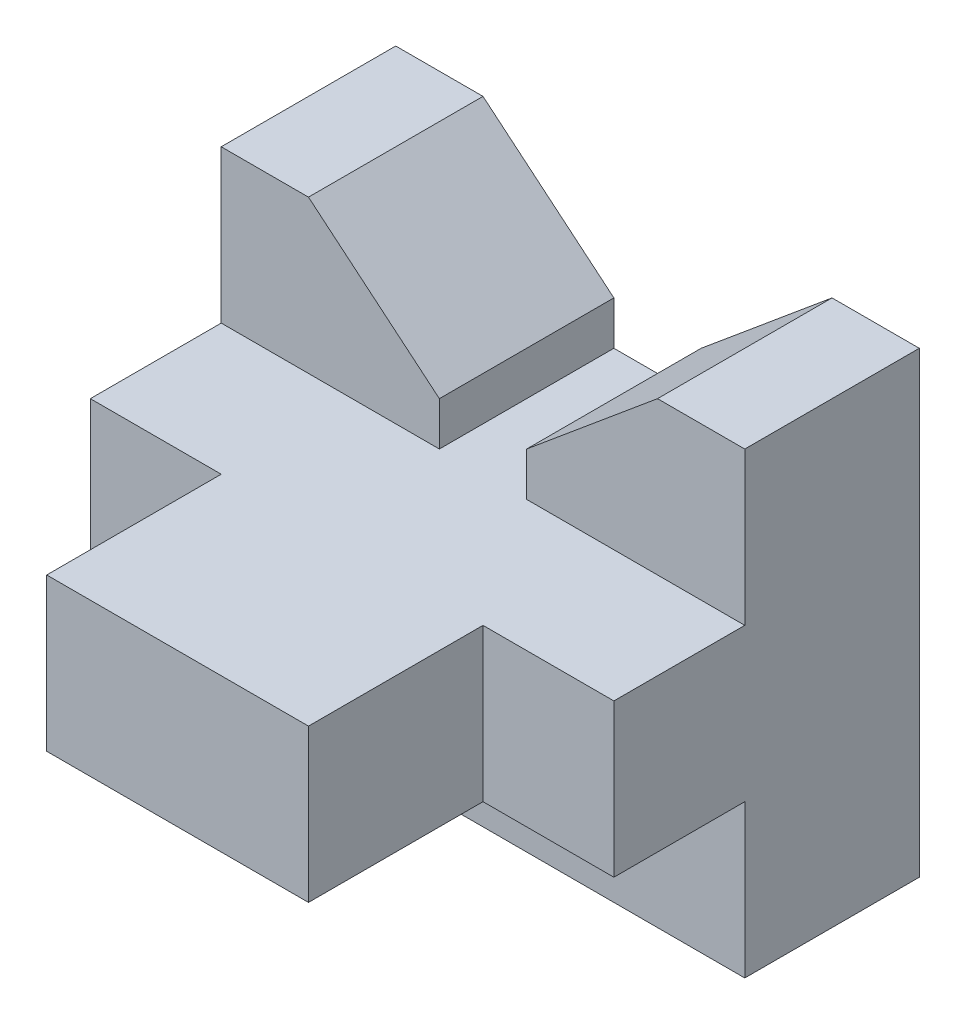
from build123d import *

# Parameters (mm, degrees)
BOSS_EXTRUDE1_DEPTH = 38.1
SKETCH2_W           = 38.1
SKETCH2_H           = 22.225
BOSS_EXTRUDE2_DEPTH = 25.4
CUT_EXTRUDE1_DEPTH  = 25.4


with BuildPart() as part:
    # Sketch1 → Boss-Extrude1 (new body, symmetric)
    with BuildSketch(Plane(origin=(0, 0, 0), x_dir=(0, 0, -1), z_dir=(1, 0, 0))):
        Polygon((-10.0584, -30.4038), (8.9916, -30.4038), (8.9916, -52.6288), (34.3916, -52.6288), (34.3916, 14.0462), (8.9916, 14.0462), (8.9916, -8.1788), (-10.0584, -8.1788), align=None)
    extrude(amount=BOSS_EXTRUDE1_DEPTH, both=True)

    # Sketch2 → Boss-Extrude2 (add)
    with BuildSketch(Plane.XY.offset(10.0584)):
        with Locations((0, -19.2913)):
            Rectangle(SKETCH2_W, SKETCH2_H)
    extrude(amount=BOSS_EXTRUDE2_DEPTH)

    # Sketch3 → Cut-Extrude1 (cut)
    with BuildSketch(Plane.XY.offset(-8.9916)):
        Polygon((6.35, -1.8288), (25.4, 14.0462), (-25.4, 14.0462), (-6.35, -1.8288), (-6.35, -8.1788), (6.35, -8.1788), align=None)
    extrude(amount=-CUT_EXTRUDE1_DEPTH, mode=Mode.SUBTRACT)


solid = part.part
